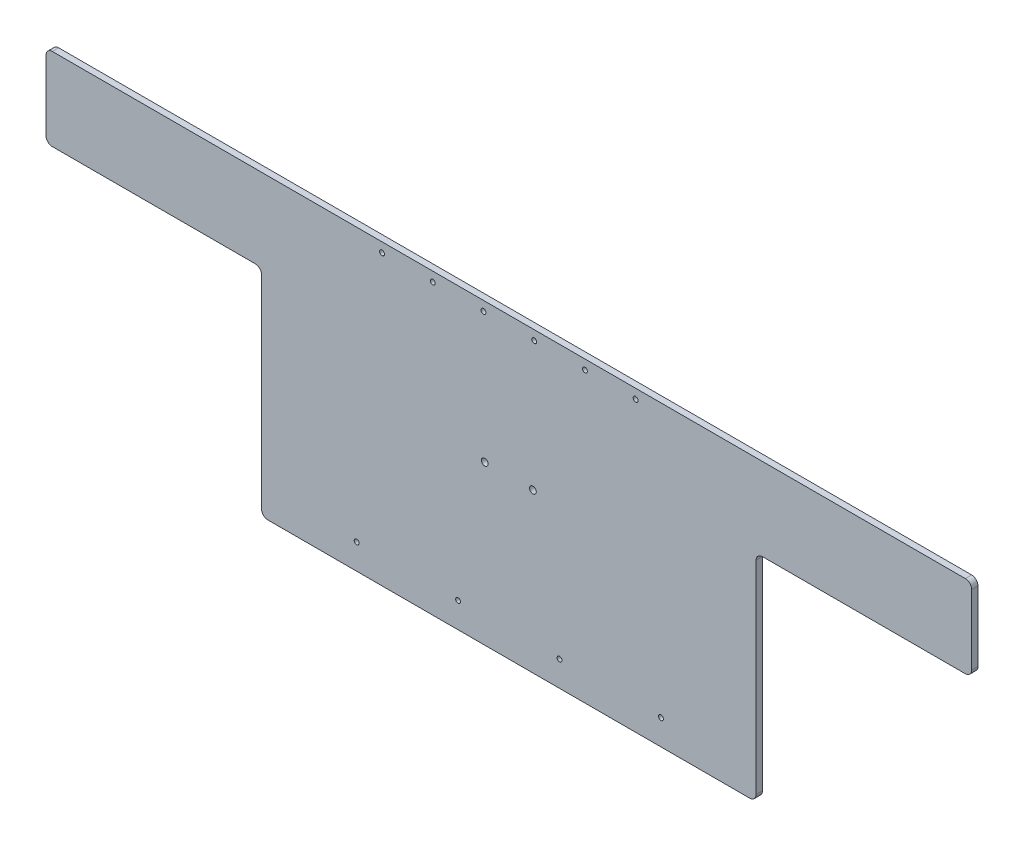
from build123d import *

# Parameters (mm, degrees)
BOSS_EXTRUDE1_DEPTH = 6.35
SKETCH2_R           = 2.4638
CUT_EXTRUDE1_DEPTH  = 7.35
LPATTERN1_COUNT     = 6
LPATTERN1_PITCH     = 50.8
SKETCH3_R           = 2.4638
CUT_EXTRUDE2_DEPTH  = 7.35
LPATTERN2_COUNT     = 4
LPATTERN2_PITCH     = 101.6
SKETCH4_R           = 3.3655
CUT_EXTRUDE3_DEPTH  = 7.35
FILLET1_R           = 6.35


with BuildPart() as part:
    # Sketch1 → Boss-Extrude1 (new body)
    with BuildSketch(Plane.XY):
        Polygon((-463.55, -82.55), (-463.55, 0), (463.55, 0), (463.55, -82.55), (247.65, -82.55), (247.65, -298.45), (-247.65, -298.45), (-247.65, -82.55), align=None)
    extrude(amount=BOSS_EXTRUDE1_DEPTH)

    # Sketch2 → Cut-Extrude1 (cut, through all)
    with BuildSketch(Plane.XY.offset(6.35)):
        with Locations((127, -9.525)):
            Circle(SKETCH2_R)
    cut_extrude1 = extrude(amount=-CUT_EXTRUDE1_DEPTH, mode=Mode.SUBTRACT)

    # LPattern1: Cut-Extrude1 ×6
    with Locations(*[(-i * LPATTERN1_PITCH, 0, 0) for i in range(1, LPATTERN1_COUNT)]):
        add(cut_extrude1, mode=Mode.SUBTRACT)

    # Sketch3 → Cut-Extrude2 (cut, through all)
    with BuildSketch(Plane.XY.offset(6.35)):
        with Locations((-152.4, -273.05)):
            Circle(SKETCH3_R)
    cut_extrude2 = extrude(amount=-CUT_EXTRUDE2_DEPTH, mode=Mode.SUBTRACT)

    # LPattern2: Cut-Extrude2 ×4
    with Locations(*[(i * LPATTERN2_PITCH, 0, 0) for i in range(1, LPATTERN2_COUNT)]):
        add(cut_extrude2, mode=Mode.SUBTRACT)

    # Sketch4 → Cut-Extrude3 (cut, through all)
    with BuildSketch(Plane.XY.offset(6.35)):
        with Locations((-24.13, -139.7)):
            Circle(SKETCH4_R)
        with Locations((24.13, -139.7)):
            Circle(SKETCH4_R)
    extrude(amount=-CUT_EXTRUDE3_DEPTH, mode=Mode.SUBTRACT)

    # Fillet1
    fillet1_edges = [part.edges().sort_by_distance(p)[0] for p in [
        (-463.55, -82.55, 3.175),
        (-463.55, 0, 3.175),
        (463.55, 0, 3.175),
        (463.55, -82.55, 3.175),
        (247.65, -82.55, 3.175),
        (247.65, -298.45, 3.175),
        (-247.65, -298.45, 3.175),
        (-247.65, -82.55, 3.175),
    ]]
    fillet(fillet1_edges, radius=FILLET1_R)


solid = part.part
